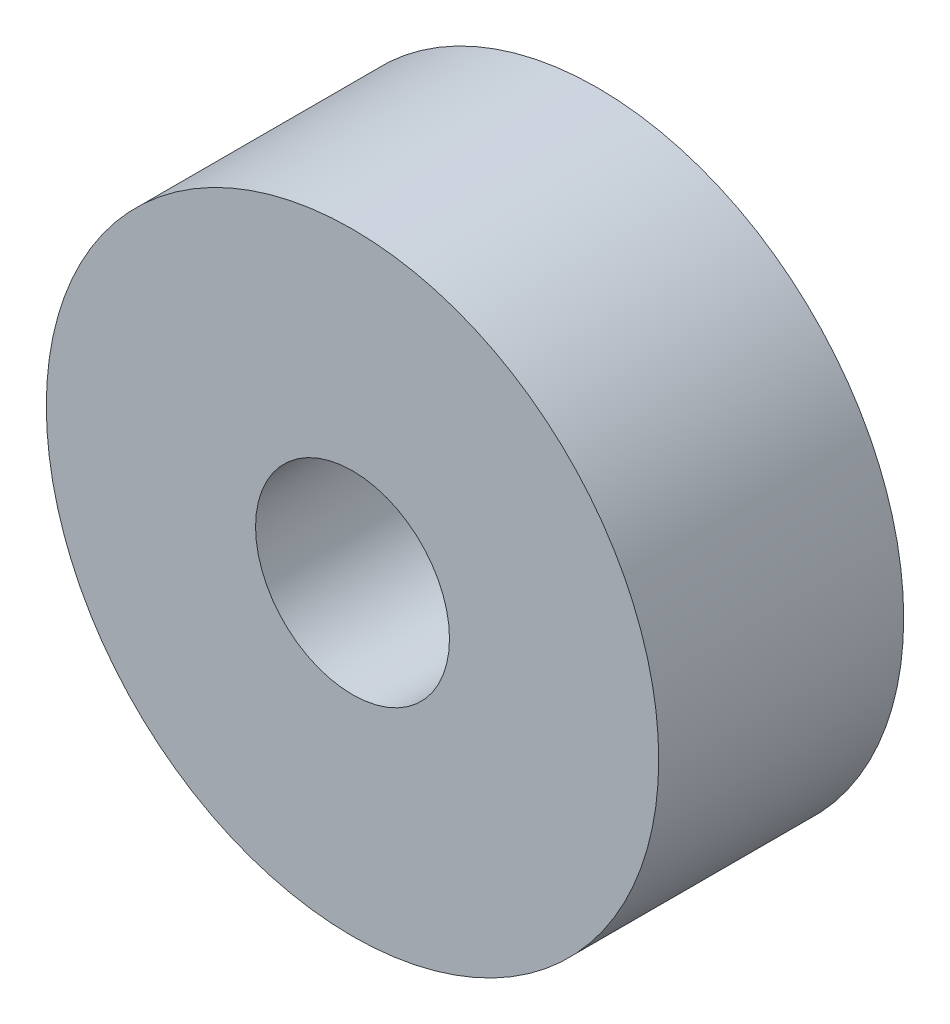
from build123d import *

# Parameters (mm, degrees)
SKETCH1_R           = 15
SKETCH1_R_2         = 4.75
BOSS_EXTRUDE1_DEPTH = 12


with BuildPart() as part:
    # Sketch1 → Boss-Extrude1 (new body)
    with BuildSketch(Plane.XY):
        Circle(SKETCH1_R)
        Circle(SKETCH1_R_2, mode=Mode.SUBTRACT)
    extrude(amount=BOSS_EXTRUDE1_DEPTH)


solid = part.part
